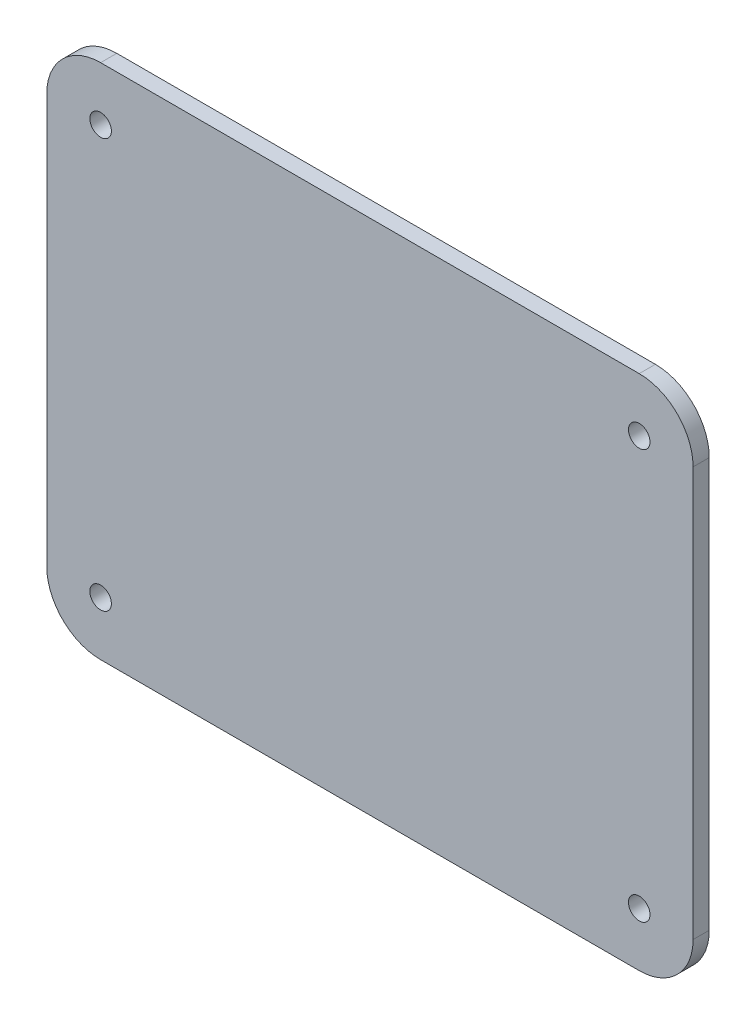
from build123d import *

# Parameters (mm, degrees)
SKETCH1_R           = 2
BOSS_EXTRUDE1_DEPTH = 3


with BuildPart() as part:
    # Sketch1 → Boss-Extrude1 (new body)
    with BuildSketch(Plane.XY):
        with BuildLine():
            Line((-50, 48), (50, 48))
            ThreePointArc((50, 48), (57.071067812, 45.071067812), (60, 38))
            Line((60, 38), (60, -38))
            ThreePointArc((60, -38), (57.071067812, -45.071067812), (50, -48))
            Line((50, -48), (-50, -48))
            ThreePointArc((-50, -48), (-57.071067812, -45.071067812), (-60, -38))
            Line((-60, -38), (-60, 38))
            ThreePointArc((-60, 38), (-57.071067812, 45.071067812), (-50, 48))
        make_face()
        with Locations((-50, 38)):
            Circle(SKETCH1_R, mode=Mode.SUBTRACT)
        with Locations((50, 38)):
            Circle(SKETCH1_R, mode=Mode.SUBTRACT)
        with Locations((50, -38)):
            Circle(SKETCH1_R, mode=Mode.SUBTRACT)
        with Locations((-50, -38)):
            Circle(SKETCH1_R, mode=Mode.SUBTRACT)
    extrude(amount=BOSS_EXTRUDE1_DEPTH)


solid = part.part
